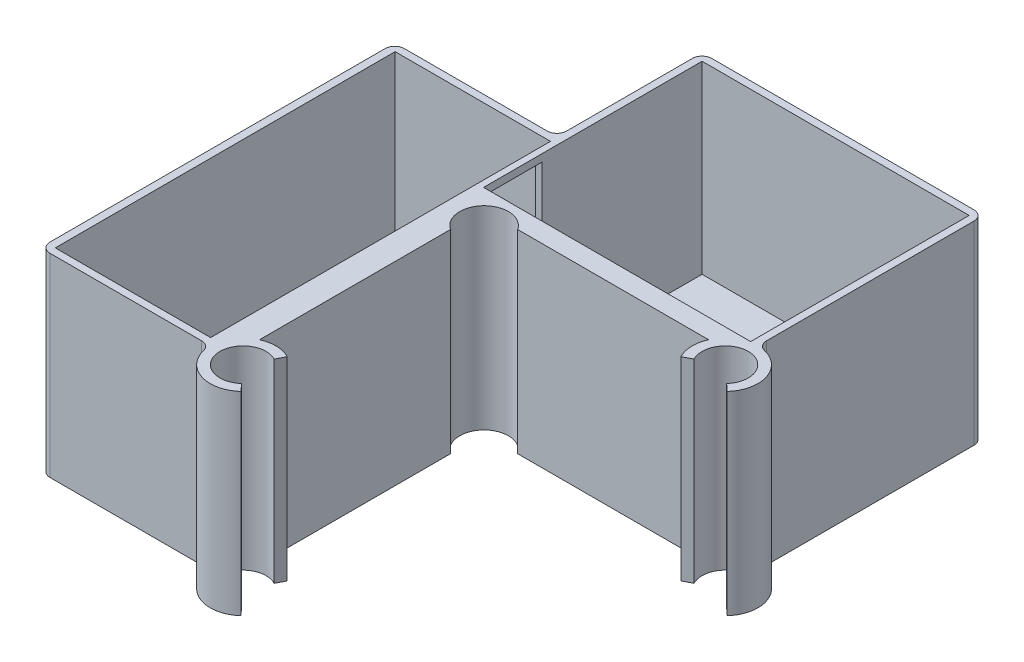
from build123d import *

# Parameters (mm, degrees)
BOSS_EXTRUDE1_DEPTH = 40
BOSS_EXTRUDE6_DEPTH = 40
CUT_EXTRUDE1_START  = 40
SKETCH9_W           = 55
SKETCH9_H           = 45
CUT_EXTRUDE1_DEPTH  = 38
CUT_EXTRUDE3_START  = 40
SKETCH10_W          = 32
SKETCH10_H          = 70
CUT_EXTRUDE3_DEPTH  = 38
FILLET4_R           = 2
SKETCH11_W          = 12
SKETCH11_H          = 36.5
CUT_EXTRUDE4_DEPTH  = 5


with BuildPart() as part:
    # Sketch1 → Boss-Extrude1 (new body)
    with BuildSketch(Plane(origin=(0, 0, 0), x_dir=(1, 0, 0), z_dir=(0, 1, 0))):
        with BuildLine():
            Line((38.137674452, -1.734509714), (-11.512325548, -1.734509714))
            ThreePointArc((-11.512325548, -1.734509714), (-16.285296321, -3.711538941), (-18.262325548, -8.484509714))
            Line((-18.262325548, -8.484509714), (-18.262325548, -58.134509714))
            ThreePointArc((-18.262325548, -58.134509714), (-14.234303537, -64.311348374), (-6.957633451, -63.116204195))
            Line((-6.957633451, -63.116204195), (-8.30717185, -61.640146571))
            ThreePointArc((-8.30717185, -61.640146571), (-16.222632836, -58.747294544), (-9.310805247, -53.925494584))
            Line((-9.310805247, -53.925494584), (-8.383849331, -52.153277687))
            ThreePointArc((-8.383849331, -52.153277687), (-11.302087657, -51.387784581), (-14.262325548, -51.970095711))
            Line((-14.262325548, -51.970095711), (-14.262325548, -12.660332986))
            ThreePointArc((-14.262325548, -12.660332986), (-15.047859454, -4.948975808), (-7.336502276, -5.734509714))
            Line((-7.336502276, -5.734509714), (31.973260449, -5.734509714))
            ThreePointArc((31.973260449, -5.734509714), (31.390949319, -8.694747605), (32.156442425, -11.612985931))
            Line((32.156442425, -11.612985931), (33.928659322, -10.686030015))
            ThreePointArc((33.928659322, -10.686030015), (38.750459282, -3.774202426), (41.643311309, -11.689663412))
            Line((41.643311309, -11.689663412), (43.119368933, -13.039201811))
            ThreePointArc((43.119368933, -13.039201811), (44.314513112, -5.762531725), (38.137674452, -1.734509714))
        make_face()
    extrude(amount=BOSS_EXTRUDE1_DEPTH)

    # Sketch8 → Boss-Extrude6 (add)
    with BuildSketch(Plane(origin=(0, 0, 0), x_dir=(1, 0, 0), z_dir=(0, 1, 0))):
        with BuildLine():
            Line((-18.262325548, -58.134509714), (-18.262325548, -8.484509714))
            ThreePointArc((-18.262325548, -8.484509714), (-16.285296321, -3.711538941), (-11.512325548, -1.734509714))
            Line((-11.512325548, -1.734509714), (38.137674452, -1.734509714))
            Line((38.137674452, -1.734509714), (38.137674452, 44.765490286))
            Line((38.137674452, 44.765490286), (-19.862325548, 44.765490286))
            Line((-19.862325548, 44.765490286), (-19.862325548, 14.865490286))
            Line((-19.862325548, 14.865490286), (-53.262325548, 14.865490286))
            Line((-53.262325548, 14.865490286), (-53.262325548, -58.134509714))
            Line((-53.262325548, -58.134509714), (-18.262325548, -58.134509714))
        make_face()
    extrude(amount=BOSS_EXTRUDE6_DEPTH)

    # Sketch9 → Cut-Extrude1 (cut)
    with BuildSketch(Plane(origin=(0, 0, 0), x_dir=(1, 0, 0), z_dir=(0, 1, 0)).offset(CUT_EXTRUDE1_START)):
        with Locations((9.137674452, 20.765490286)):
            Rectangle(SKETCH9_W, SKETCH9_H)
    extrude(amount=-CUT_EXTRUDE1_DEPTH, mode=Mode.SUBTRACT)

    # Sketch10 → Cut-Extrude3 (cut)
    with BuildSketch(Plane(origin=(0, 0, 0), x_dir=(1, 0, 0), z_dir=(0, 1, 0)).offset(CUT_EXTRUDE3_START)):
        with Locations((-35.681852139, -21.634509714)):
            Rectangle(SKETCH10_W, SKETCH10_H)
    extrude(amount=-CUT_EXTRUDE3_DEPTH, mode=Mode.SUBTRACT)

    # Fillet4
    fillet4_edges = [part.edges().sort_by_distance(p)[0] for p in [
        (-18.262325548, 20, 58.134509714),
        (38.137674452, 20, 1.734509714),
        (38.137674452, 20, -44.765490286),
        (-19.862325548, 20, -44.765490286),
        (-19.862325548, 20, -14.865490286),
        (-53.262325548, 20, -14.865490286),
        (-53.262325548, 20, 58.134509714),
    ]]
    fillet(fillet4_edges, radius=FILLET4_R)

    # Sketch11 → Cut-Extrude4 (cut)
    with BuildSketch(Plane(origin=(-18.362325548, 0, 0), x_dir=(0, 0, -1), z_dir=(1, 0, 0))):
        with Locations((4.265490286, 20.25)):
            Rectangle(SKETCH11_W, SKETCH11_H)
    extrude(amount=-CUT_EXTRUDE4_DEPTH, mode=Mode.SUBTRACT)


solid = part.part
